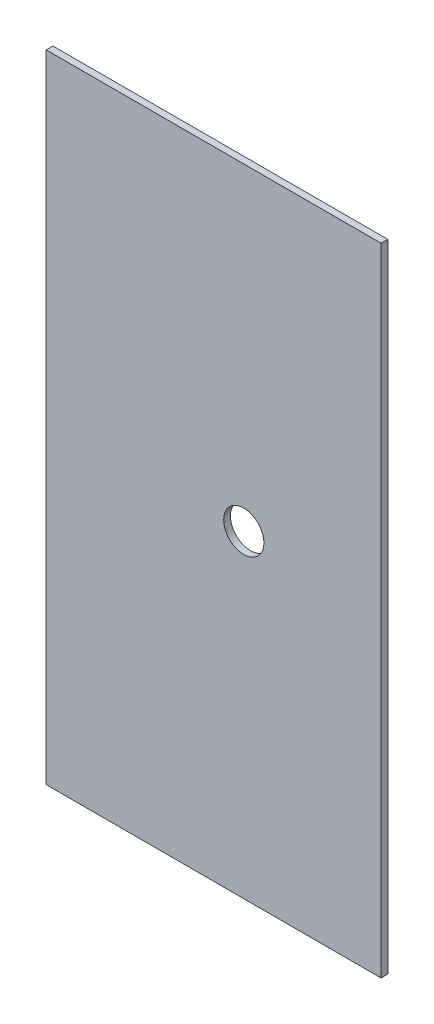
from build123d import *

# Parameters (mm, degrees)
SKETCH1_W           = 100
SKETCH1_H           = 190
BOSS_EXTRUDE1_DEPTH = 2
SKETCH2_R           = 6
CUT_EXTRUDE1_DEPTH  = 2


with BuildPart() as part:
    # Sketch1 → Boss-Extrude1 (new body)
    with BuildSketch(Plane.XY):
        Rectangle(SKETCH1_W, SKETCH1_H)
    extrude(amount=BOSS_EXTRUDE1_DEPTH)

    # Sketch2 → Cut-Extrude1 (cut)
    with BuildSketch(Plane(origin=(0, 0, 0), x_dir=(-1, 0, 0), z_dir=(0, 0, -1))):
        with Locations((-9, 0)):
            Circle(SKETCH2_R)
    extrude(amount=-CUT_EXTRUDE1_DEPTH, mode=Mode.SUBTRACT)


solid = part.part
